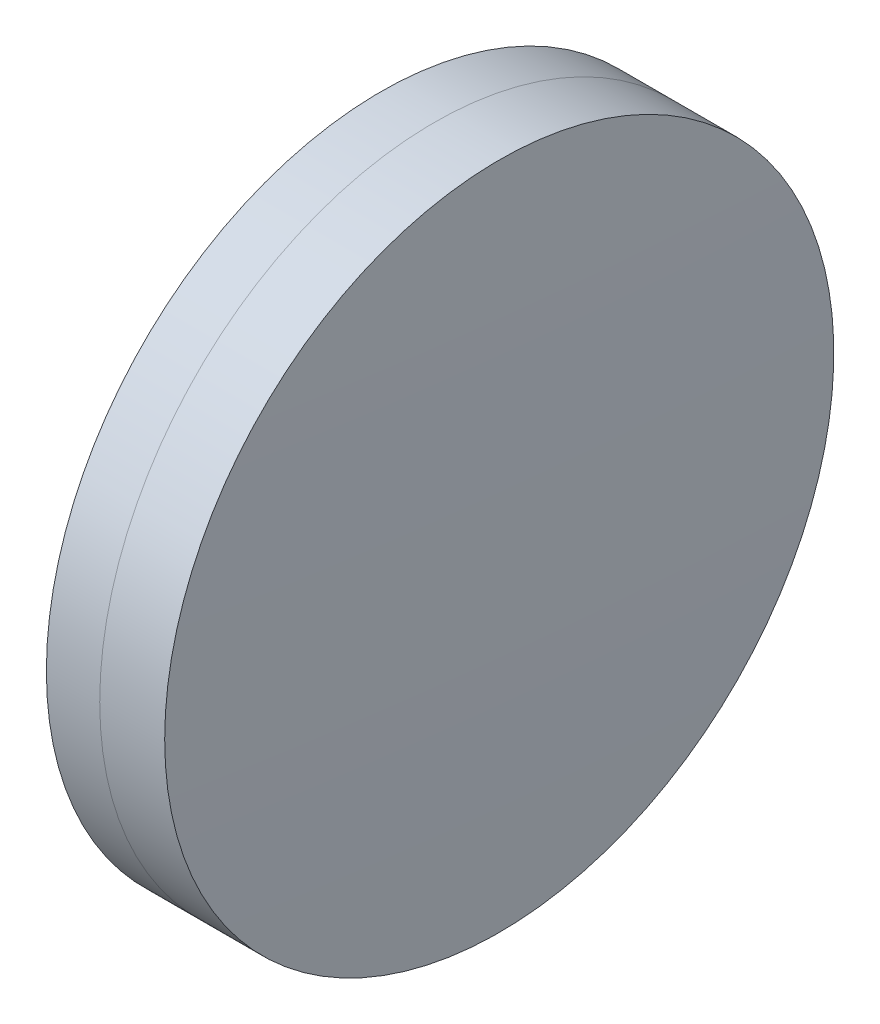
from build123d import *


with BuildPart() as part:
    # 草图1 one side → 旋转1 (revolve)
    with BuildSketch(Plane(origin=(0, 0, 0), x_dir=(1, 0, 0), z_dir=(0, 1, 0)), mode=Mode.PRIVATE) as revolve_1_sk:
        with BuildLine():
            ThreePointArc((140.053482329, 12.5), (139.750648638, 6.253260454), (139.649668974, 0))
            Line((139.649668974, 0), (142.659668974, 0))
            ThreePointArc((142.659668974, 0), (142.50635896, 6.257507737), (142.046796801, 12.5))
            Line((142.046796801, 12.5), (140.053482329, 12.5))
        make_face()
    revolve(revolve_1_sk.sketch.rotate(Axis((-9.702612178, 0, 0), (1, 0, 0)), 180), axis=Axis((-9.702612178, 0, 0), (1, 0, 0)))  # turned: the seam where the file's is


with BuildPart() as body_2:
    # 草图2 one side → 旋转3 (revolve)
    with BuildSketch(Plane(origin=(0, 0, 0), x_dir=(1, 0, 0), z_dir=(0, 1, 0)), mode=Mode.PRIVATE) as revolve_3_sk:
        with BuildLine():
            Line((144.47385929, 12.5), (142.046796801, 12.5))
            ThreePointArc((142.046796801, 12.5), (142.50635896, 6.257507737), (142.659668974, 0))
            Line((142.659668974, 0), (144.659668974, 0))
            ThreePointArc((144.659668974, 0), (144.613213987, 6.250690467), (144.47385929, 12.5))
        make_face()
    revolve(revolve_3_sk.sketch.rotate(Axis((-0.551919993, 0, 0), (1, 0, 0)), 180), axis=Axis((-0.551919993, 0, 0), (1, 0, 0)))  # turned: the seam where the file's is


solid = Compound([part.part, body_2.part])
